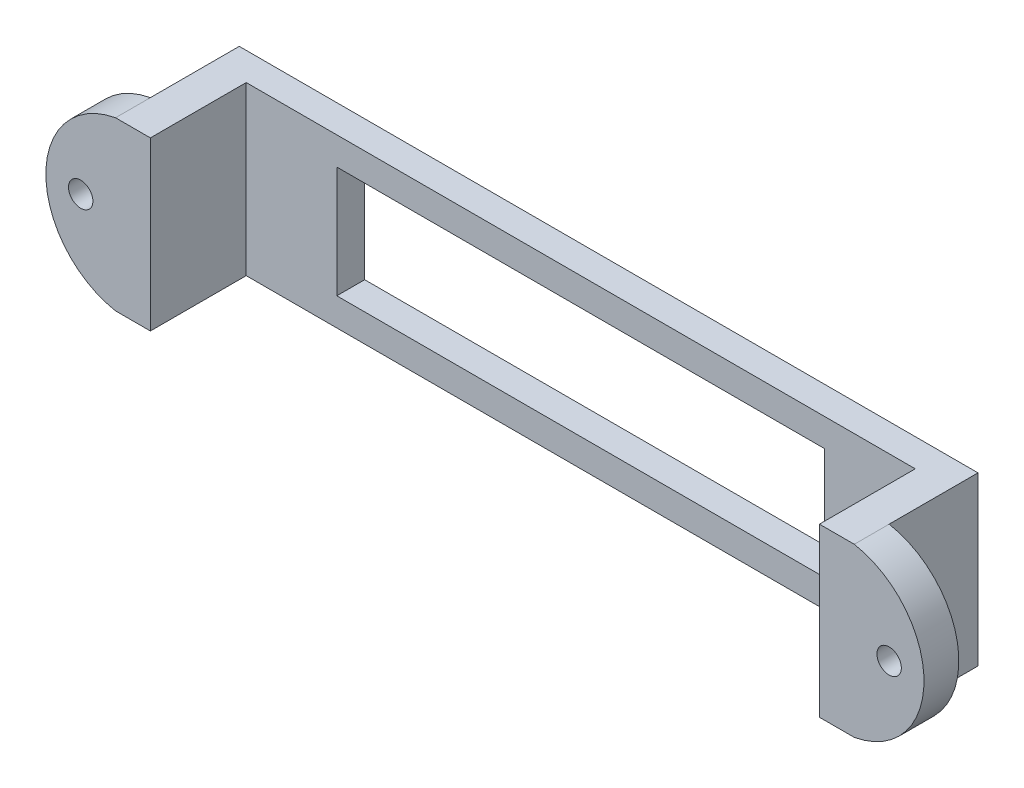
from build123d import *

# Parameters (mm, degrees)
ESQUISSE1_W             = 5
ESQUISSE1_H             = 24
ESQUISSE1_W_2           = 96
ESQUISSE1_W_3           = 70
ESQUISSE1_H_2           = 16
BOSS_EXTRU_1_DEPTH      = 4
ESQUISSE2_W             = 5
ESQUISSE2_H             = 24
BOSS_EXTRU_2_DEPTH      = 8.75
BOSS_EXTRU_3_DEPTH      = 5
ESQUISSE4_R             = 1.75
ENL_V_MAT_EXTRU_2_DEPTH = 18.75


with BuildPart() as part:
    # Esquisse1 → Boss.-Extru.1 (new body)
    with BuildSketch(Plane.XY):
        with Locations((-50.5, 0)):
            Rectangle(ESQUISSE1_W, ESQUISSE1_H)
        Rectangle(ESQUISSE1_W_2, ESQUISSE1_H)
        Rectangle(ESQUISSE1_W_3, ESQUISSE1_H_2, mode=Mode.SUBTRACT)
        with Locations((50.5, 0)):
            Rectangle(ESQUISSE1_W, ESQUISSE1_H)
    extrude(amount=BOSS_EXTRU_1_DEPTH)

    # Esquisse2 → Boss.-Extru.2 (add)
    with BuildSketch(Plane.XY.offset(4)):
        with Locations((-50.5, 0)):
            Rectangle(ESQUISSE2_W, ESQUISSE2_H)
        with Locations((50.5, 0)):
            Rectangle(ESQUISSE2_W, ESQUISSE2_H)
    extrude(amount=BOSS_EXTRU_2_DEPTH)

    # Esquisse3 → Boss.-Extru.3 (add)
    with BuildSketch(Plane.XY.offset(12.75)):
        with BuildLine():
            Line((-48, 12), (-53, 12))
            ThreePointArc((-53, 12), (-63, 0), (-53, -12))
            Line((-53, -12), (-48, -12))
            Line((-48, -12), (-48, 12))
        make_face()
        with BuildLine():
            Line((48, -12), (53, -12))
            ThreePointArc((53, -12), (63, 0), (53, 12))
            Line((53, 12), (48, 12))
            Line((48, 12), (48, -12))
        make_face()
    extrude(amount=BOSS_EXTRU_3_DEPTH)

    # Esquisse4 → Enlèv. mat.-Extru.2 (cut, through all)
    with BuildSketch(Plane.XY.offset(17.75)):
        with Locations((-58, 0)):
            Circle(ESQUISSE4_R)
        with Locations((58, 0)):
            Circle(ESQUISSE4_R)
    extrude(amount=-ENL_V_MAT_EXTRU_2_DEPTH, mode=Mode.SUBTRACT)


solid = part.part
